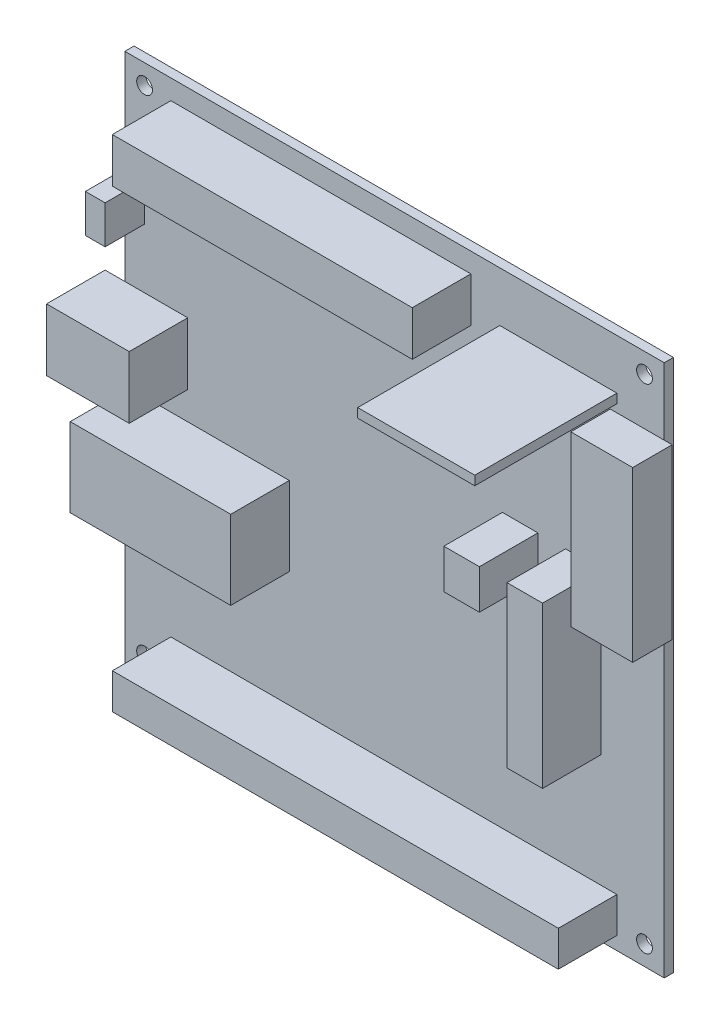
from build123d import *

# Parameters (mm, degrees)
SKETCH1_W           = 104.14
SKETCH1_H           = 102.87
SKETCH1_R           = 1.524
BOSS_EXTRUDE1_DEPTH = 1.778
SKETCH2_W           = 57.912
SKETCH2_H           = 8.636
SKETCH2_W_2         = 15.9512
SKETCH2_H_2         = 12
SKETCH2_W_3         = 30.988
SKETCH2_H_3         = 15.24
SKETCH2_W_4         = 86.106
SKETCH2_H_4         = 6.858
SKETCH2_W_5         = 6.858
SKETCH2_H_5         = 30.988
SKETCH2_H_6         = 7.62
BOSS_EXTRUDE2_DEPTH = 11.303
SKETCH3_W           = 11.938
SKETCH3_H           = 32.58
SKETCH3_W_2         = 3.81
SKETCH3_H_2         = 7.366
BOSS_EXTRUDE3_DEPTH = 7.62
SKETCH4_R           = 1.74625
BOSS_EXTRUDE4_DEPTH = 0.762
SKETCH5_W           = 22.606
SKETCH5_H           = 1.778
BOSS_EXTRUDE5_DEPTH = 27.432


with BuildPart() as part:
    # Sketch1 → Boss-Extrude1 (new body)
    with BuildSketch(Plane.XY):
        Rectangle(SKETCH1_W, SKETCH1_H)
        with Locations((-48.26, 47.625)):
            Circle(SKETCH1_R, mode=Mode.SUBTRACT)
        with Locations((48.26, 47.625)):
            Circle(SKETCH1_R, mode=Mode.SUBTRACT)
        with Locations((48.26, -47.625)):
            Circle(SKETCH1_R, mode=Mode.SUBTRACT)
        with Locations((-48.26, -47.625)):
            Circle(SKETCH1_R, mode=Mode.SUBTRACT)
    extrude(amount=BOSS_EXTRUDE1_DEPTH)

    # Sketch2 → Boss-Extrude2 (add)
    with BuildSketch(Plane.XY.offset(1.778)):
        with Locations((-14.224, 43.307)):
            Rectangle(SKETCH2_W, SKETCH2_H)
        with Locations((-47.9044, 6.955)):
            Rectangle(SKETCH2_W_2, SKETCH2_H_2)
        with Locations((-35.814, -12.065)):
            Rectangle(SKETCH2_W_3, SKETCH2_H_3)
        with Locations((-0.127, -45.466)):
            Rectangle(SKETCH2_W_4, SKETCH2_H_4)
        with Locations((36.449, -4.699)):
            Rectangle(SKETCH2_W_5, SKETCH2_H_5)
        with Locations((24.257, 6.985)):
            Rectangle(SKETCH2_W_5, SKETCH2_H_6)
    extrude(amount=BOSS_EXTRUDE2_DEPTH)

    # Sketch3 → Boss-Extrude3 (add)
    with BuildSketch(Plane.XY.offset(1.778)):
        with Locations((47.625, 22.195)):
            Rectangle(SKETCH3_W, SKETCH3_H)
        with Locations((-50.165, 28.135)):
            Rectangle(SKETCH3_W_2, SKETCH3_H_2)
    extrude(amount=BOSS_EXTRUDE3_DEPTH)

    # Sketch4 → Boss-Extrude4 (add)
    with BuildSketch(Plane.ZY.offset(52.07)):
        with Locations(Location((6.096, 28.135, 0), (0, 0, 90))):  # turned: the seam where the file's is
            Circle(SKETCH4_R)
    extrude(amount=BOSS_EXTRUDE4_DEPTH)

    # Sketch5 → Boss-Extrude5 (add)
    with BuildSketch(Plane.XY.offset(1.778)):
        with Locations((31.623, 40.894)):
            Rectangle(SKETCH5_W, SKETCH5_H)
    extrude(amount=BOSS_EXTRUDE5_DEPTH)


solid = part.part
